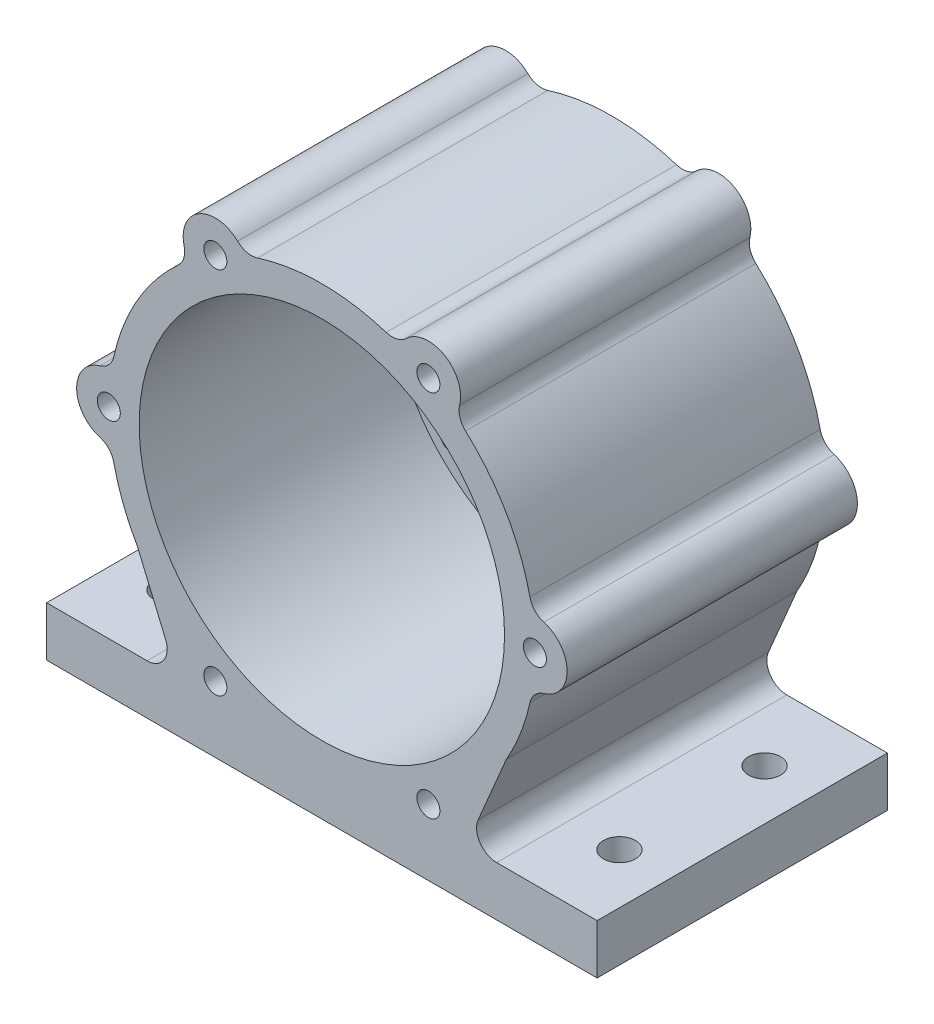
from build123d import *

# Parameters (mm, degrees)
SKETCH1_R          = 24.5
SKETCH1_R_2        = 18.25
SKETCH1_R_3        = 1.15
SHELL_DEPTH        = 25
SKETCH2_R          = 24.5
SKETCH2_R_2        = 7.25
FRONT_FACE_DEPTH   = 4
FRONT_CUTOUT_REACH = 6
SKETCH4_R          = 47.662940576
CUT_EXTRUDE2_DEPTH = 30
FOOT_DEPTH         = 29
CUT_EXTRUDE3_REACH = 6.965
SKETCH6_R          = 1.6


with BuildPart() as part:
    # Sketch1 → Shell (new body)
    with BuildSketch(Plane.XY):
        Circle(SKETCH1_R)
        Circle(SKETCH1_R_2, mode=Mode.SUBTRACT)
        with Locations((10.6425, 18.43335072)):
            Circle(SKETCH1_R_3, mode=Mode.SUBTRACT)
        with Locations((21.285, 0)):
            Circle(SKETCH1_R_3, mode=Mode.SUBTRACT)
        with Locations((10.6425, -18.43335072)):
            Circle(SKETCH1_R_3, mode=Mode.SUBTRACT)
        with Locations((-10.6425, -18.43335072)):
            Circle(SKETCH1_R_3, mode=Mode.SUBTRACT)
        with Locations((-21.285, 0)):
            Circle(SKETCH1_R_3, mode=Mode.SUBTRACT)
        with Locations((-10.6425, 18.43335072)):
            Circle(SKETCH1_R_3, mode=Mode.SUBTRACT)
    extrude(amount=SHELL_DEPTH)

    # Sketch2 → Front Face (add)
    with BuildSketch(Plane(origin=(0, 0, 0), x_dir=(-1, 0, 0), z_dir=(0, 0, -1))):
        Circle(SKETCH2_R)
        Circle(SKETCH2_R_2, mode=Mode.SUBTRACT)
    extrude(amount=FRONT_FACE_DEPTH)

    # Sketch3 → Front Cutout (cut, up to next)
    with BuildSketch(Plane.XY, mode=Mode.PRIVATE) as front_cutout_sk1:
        with BuildLine():
            Line((2.9546421, 10.808626061), (4.278048129, 15.64463523))
            ThreePointArc((4.278048129, 15.64463523), (4.166472664, 16.430562443), (3.517420663, 16.88757685))
            ThreePointArc((3.517420663, 16.88757685), (-0.005796994, 17.249999026), (-3.528770265, 16.885208924))
            ThreePointArc((-3.528770265, 16.885208924), (-4.174553562, 16.432574254), (-4.291492303, 15.652677119))
            Line((-4.291492303, 15.652677119), (-3.020759373, 10.807322517))
            ThreePointArc((-3.020759373, 10.807322517), (-2.58920538, 10.216615101), (-1.870940192, 10.077801486))
            ThreePointArc((-1.870940192, 10.077801486), (-0.029343923, 10.249957997), (1.813207862, 10.088348589))
            ThreePointArc((1.813207862, 10.088348589), (2.523766335, 10.226878689), (2.9546421, 10.808626061))
        make_face()
    front_cutout_tool1 = extrude(front_cutout_sk1.sketch, amount=-FRONT_CUTOUT_REACH, mode=Mode.PRIVATE) & part.part
    add(front_cutout_tool1.solids().sort_by_distance((-0.016979, 13.876247, 0))[0], mode=Mode.SUBTRACT)
    # Sketch3 → Front Cutout (cut, up to next)
    with BuildSketch(Plane.XY, mode=Mode.PRIVATE) as front_cutout_sk2:
        with BuildLine():
            Line((10.837865799, 2.845517913), (15.687675607, 4.117419256))
            ThreePointArc((15.687675607, 4.117419256), (16.312520806, 4.60701005), (16.383780892, 5.397612775))
            ThreePointArc((16.383780892, 5.397612775), (14.936038875, 8.630019857), (12.858634744, 11.498609156))
            ThreePointArc((12.858634744, 11.498609156), (12.143749973, 11.831556562), (11.409869871, 11.542879914))
            Line((11.409869871, 11.542879914), (7.849036161, 8.019715614))
            ThreePointArc((7.849036161, 8.019715614), (7.553245528, 7.350625185), (7.792162005, 6.659182478))
            ThreePointArc((7.792162005, 6.659182478), (8.862052051, 5.150391581), (9.643370091, 3.473890223))
            ThreePointArc((9.643370091, 3.473890223), (10.118619913, 2.927793585), (10.837865799, 2.845517913))
        make_face()
    front_cutout_tool2 = extrude(front_cutout_sk2.sketch, amount=-FRONT_CUTOUT_REACH, mode=Mode.PRIVATE) & part.part
    add(front_cutout_tool2.solids().sort_by_distance((12.008692, 6.952828, 0))[0], mode=Mode.SUBTRACT)
    # Sketch3 → Front Cutout (cut, up to next)
    with BuildSketch(Plane.XY, mode=Mode.PRIVATE) as front_cutout_sk3:
        with BuildLine():
            Line((7.883223699, -7.963108149), (11.409627477, -11.527215974))
            ThreePointArc((11.409627477, -11.527215974), (12.146048142, -11.823552392), (12.866360229, -11.489964075))
            ThreePointArc((12.866360229, -11.489964075), (14.941835869, -8.619979169), (16.387405009, -5.386599768))
            ThreePointArc((16.387405009, -5.386599768), (16.318303535, -4.601017693), (15.701362174, -4.109797205))
            Line((15.701362174, -4.109797205), (10.869795533, -2.787606903))
            ThreePointArc((10.869795533, -2.787606903), (10.142450908, -2.865989916), (9.663102197, -3.418619008))
            ThreePointArc((9.663102197, -3.418619008), (8.891395974, -5.099566416), (7.830162229, -6.614458365))
            ThreePointArc((7.830162229, -6.614458365), (7.594853579, -7.299085103), (7.883223699, -7.963108149))
        make_face()
    front_cutout_tool3 = extrude(front_cutout_sk3.sketch, amount=-FRONT_CUTOUT_REACH, mode=Mode.PRIVATE) & part.part
    add(front_cutout_tool3.solids().sort_by_distance((12.025672, -6.923419, 0))[0], mode=Mode.SUBTRACT)
    # Sketch3 → Front Cutout (cut, up to next)
    with BuildSketch(Plane.XY, mode=Mode.PRIVATE) as front_cutout_sk4:
        with BuildLine():
            Line((-2.9546421, -10.808626061), (-4.278048129, -15.64463523))
            ThreePointArc((-4.278048129, -15.64463523), (-4.166472664, -16.430562443), (-3.517420663, -16.88757685))
            ThreePointArc((-3.517420663, -16.88757685), (0.005796994, -17.249999026), (3.528770265, -16.885208924))
            ThreePointArc((3.528770265, -16.885208924), (4.174553562, -16.432574254), (4.291492303, -15.652677119))
            Line((4.291492303, -15.652677119), (3.020759373, -10.807322517))
            ThreePointArc((3.020759373, -10.807322517), (2.58920538, -10.216615101), (1.870940192, -10.077801486))
            ThreePointArc((1.870940192, -10.077801486), (0.029343923, -10.249957997), (-1.813207862, -10.088348589))
            ThreePointArc((-1.813207862, -10.088348589), (-2.523766335, -10.226878689), (-2.9546421, -10.808626061))
        make_face()
    front_cutout_tool4 = extrude(front_cutout_sk4.sketch, amount=-FRONT_CUTOUT_REACH, mode=Mode.PRIVATE) & part.part
    add(front_cutout_tool4.solids().sort_by_distance((0.016979, -13.876247, 0))[0], mode=Mode.SUBTRACT)
    # Sketch3 → Front Cutout (cut, up to next)
    with BuildSketch(Plane.XY, mode=Mode.PRIVATE) as front_cutout_sk5:
        with BuildLine():
            Line((-10.837865799, -2.845517913), (-15.687675607, -4.117419256))
            ThreePointArc((-15.687675607, -4.117419256), (-16.312520806, -4.60701005), (-16.383780892, -5.397612775))
            ThreePointArc((-16.383780892, -5.397612775), (-14.936038875, -8.630019857), (-12.858634744, -11.498609156))
            ThreePointArc((-12.858634744, -11.498609156), (-12.143749973, -11.831556562), (-11.409869871, -11.542879914))
            Line((-11.409869871, -11.542879914), (-7.849036161, -8.019715614))
            ThreePointArc((-7.849036161, -8.019715614), (-7.553245528, -7.350625185), (-7.792162005, -6.659182478))
            ThreePointArc((-7.792162005, -6.659182478), (-8.862052051, -5.150391581), (-9.643370091, -3.473890223))
            ThreePointArc((-9.643370091, -3.473890223), (-10.118619913, -2.927793585), (-10.837865799, -2.845517913))
        make_face()
    front_cutout_tool5 = extrude(front_cutout_sk5.sketch, amount=-FRONT_CUTOUT_REACH, mode=Mode.PRIVATE) & part.part
    add(front_cutout_tool5.solids().sort_by_distance((-12.008692, -6.952828, 0))[0], mode=Mode.SUBTRACT)
    # Sketch3 → Front Cutout (cut, up to next)
    with BuildSketch(Plane.XY, mode=Mode.PRIVATE) as front_cutout_sk6:
        with BuildLine():
            Line((-7.883223699, 7.963108149), (-11.409627477, 11.527215974))
            ThreePointArc((-11.409627477, 11.527215974), (-12.146048142, 11.823552392), (-12.866360229, 11.489964075))
            ThreePointArc((-12.866360229, 11.489964075), (-14.941835869, 8.619979169), (-16.387405009, 5.386599768))
            ThreePointArc((-16.387405009, 5.386599768), (-16.318303535, 4.601017693), (-15.701362174, 4.109797205))
            Line((-15.701362174, 4.109797205), (-10.869795533, 2.787606903))
            ThreePointArc((-10.869795533, 2.787606903), (-10.142450908, 2.865989916), (-9.663102197, 3.418619008))
            ThreePointArc((-9.663102197, 3.418619008), (-8.891395974, 5.099566416), (-7.830162229, 6.614458365))
            ThreePointArc((-7.830162229, 6.614458365), (-7.594853579, 7.299085103), (-7.883223699, 7.963108149))
        make_face()
    front_cutout_tool6 = extrude(front_cutout_sk6.sketch, amount=-FRONT_CUTOUT_REACH, mode=Mode.PRIVATE) & part.part
    add(front_cutout_tool6.solids().sort_by_distance((-12.025672, 6.923419, 0))[0], mode=Mode.SUBTRACT)

    # Sketch4 → Cut-Extrude2 (cut, through all)
    with BuildSketch(Plane.XY.offset(25)):
        Circle(SKETCH4_R)
        with BuildLine():
            ThreePointArc((-14.357896922, 15.713116209), (-18.43335072, 10.6425), (-20.78690627, 4.577745375))
            ThreePointArc((-20.78690627, 4.577745375), (-21.279990354, 3.641110586), (-22.182058329, 3.087314586))
            ThreePointArc((-22.182058329, 3.087314586), (-24.5, 0), (-22.182058329, -3.087314586))
            ThreePointArc((-22.182058329, -3.087314586), (-21.279990354, -3.641110586), (-20.78690627, -4.577745375))
            ThreePointArc((-20.78690627, -4.577745375), (-18.43335072, -10.6425), (-14.357896922, -15.713116209))
            ThreePointArc((-14.357896922, -15.713116209), (-13.793289442, -16.608456946), (-13.764722026, -17.666568728))
            ThreePointArc((-13.764722026, -17.666568728), (-12.25, -21.217622393), (-8.417336304, -20.753883315))
            ThreePointArc((-8.417336304, -20.753883315), (-7.486700912, -20.249567531), (-6.429009348, -20.290861583))
            ThreePointArc((-6.429009348, -20.290861583), (0, -21.285), (6.429009348, -20.290861583))
            ThreePointArc((6.429009348, -20.290861583), (7.486700912, -20.249567531), (8.417336304, -20.753883315))
            ThreePointArc((8.417336304, -20.753883315), (12.25, -21.217622393), (13.764722026, -17.666568728))
            ThreePointArc((13.764722026, -17.666568728), (13.793289442, -16.608456946), (14.357896922, -15.713116209))
            ThreePointArc((14.357896922, -15.713116209), (18.43335072, -10.6425), (20.78690627, -4.577745375))
            ThreePointArc((20.78690627, -4.577745375), (21.279990354, -3.641110586), (22.182058329, -3.087314586))
            ThreePointArc((22.182058329, -3.087314586), (24.5, 0), (22.182058329, 3.087314586))
            ThreePointArc((22.182058329, 3.087314586), (21.279990354, 3.641110586), (20.78690627, 4.577745375))
            ThreePointArc((20.78690627, 4.577745375), (18.43335072, 10.6425), (14.357896922, 15.713116209))
            ThreePointArc((14.357896922, 15.713116209), (13.793289442, 16.608456946), (13.764722026, 17.666568728))
            ThreePointArc((13.764722026, 17.666568728), (12.25, 21.217622393), (8.417336304, 20.753883315))
            ThreePointArc((8.417336304, 20.753883315), (7.486700912, 20.249567531), (6.429009348, 20.290861583))
            ThreePointArc((6.429009348, 20.290861583), (0, 21.285), (-6.429009348, 20.290861583))
            ThreePointArc((-6.429009348, 20.290861583), (-7.486700912, 20.249567531), (-8.417336304, 20.753883315))
            ThreePointArc((-8.417336304, 20.753883315), (-12.25, 21.217622393), (-13.764722026, 17.666568728))
            ThreePointArc((-13.764722026, 17.666568728), (-13.793289442, 16.608456946), (-14.357896922, 15.713116209))
        make_face(mode=Mode.SUBTRACT)
    extrude(amount=-CUT_EXTRUDE2_DEPTH, mode=Mode.SUBTRACT)

    # Sketch5 → Foot (add)
    with BuildSketch(Plane.XY.offset(25)):
        with BuildLine():
            Line((-27.5, -25.036296311), (27.5, -25.036296311))
            Line((27.5, -25.036296311), (27.5, -20.070839215))
            Line((27.5, -20.070839215), (17.456181219, -20.070839215))
            ThreePointArc((17.456181219, -20.070839215), (15.788638495, -19.175058967), (15.614847604, -17.290140477))
            Line((15.614847604, -17.290140477), (18.43335072, -10.6425))
            ThreePointArc((18.43335072, -10.6425), (16.590487264, -13.334427522), (14.357896922, -15.713116209))
            ThreePointArc((14.357896922, -15.713116209), (13.793289442, -16.608456946), (13.764722026, -17.666568728))
            ThreePointArc((13.764722026, -17.666568728), (12.25, -21.217622393), (8.417336304, -20.753883315))
            ThreePointArc((8.417336304, -20.753883315), (7.486700912, -20.249567531), (6.429009348, -20.290861583))
            ThreePointArc((6.429009348, -20.290861583), (0, -21.285), (-6.429009348, -20.290861583))
            ThreePointArc((-6.429009348, -20.290861583), (-7.486700912, -20.249567531), (-8.417336304, -20.753883315))
            ThreePointArc((-8.417336304, -20.753883315), (-12.25, -21.217622393), (-13.764722026, -17.666568728))
            ThreePointArc((-13.764722026, -17.666568728), (-13.793289442, -16.608456946), (-14.357896922, -15.713116209))
            ThreePointArc((-14.357896922, -15.713116209), (-16.590487264, -13.334427522), (-18.43335072, -10.6425))
            Line((-18.43335072, -10.6425), (-15.614847604, -17.290140477))
            ThreePointArc((-15.614847604, -17.290140477), (-15.788638495, -19.175058967), (-17.456181219, -20.070839215))
            Line((-17.456181219, -20.070839215), (-27.5, -20.070839215))
            Line((-27.5, -20.070839215), (-27.5, -25.036296311))
        make_face()
    extrude(amount=-FOOT_DEPTH)

    # Sketch6 → Cut-Extrude3 (cut, up to next)
    with BuildSketch(Plane(origin=(0, -20.070839215, 0), x_dir=(1, 0, 0), z_dir=(0, 1, 0)), mode=Mode.PRIVATE) as cut_extrude3_sk1:
        with Locations((22.47809061, -17.75)):
            Circle(SKETCH6_R)
    cut_extrude3_tool1 = extrude(cut_extrude3_sk1.sketch, amount=-CUT_EXTRUDE3_REACH, mode=Mode.PRIVATE) & part.part
    add(cut_extrude3_tool1.solids().sort_by_distance((22.478091, -20.070839, 17.75))[0], mode=Mode.SUBTRACT)
    # Sketch6 → Cut-Extrude3 (cut, up to next)
    with BuildSketch(Plane(origin=(0, -20.070839215, 0), x_dir=(1, 0, 0), z_dir=(0, 1, 0)), mode=Mode.PRIVATE) as cut_extrude3_sk2:
        with Locations((22.47809061, -3.25)):
            Circle(SKETCH6_R)
    cut_extrude3_tool2 = extrude(cut_extrude3_sk2.sketch, amount=-CUT_EXTRUDE3_REACH, mode=Mode.PRIVATE) & part.part
    add(cut_extrude3_tool2.solids().sort_by_distance((22.478091, -20.070839, 3.25))[0], mode=Mode.SUBTRACT)
    # Sketch6 → Cut-Extrude3 (cut, up to next)
    with BuildSketch(Plane(origin=(0, -20.070839215, 0), x_dir=(1, 0, 0), z_dir=(0, 1, 0)), mode=Mode.PRIVATE) as cut_extrude3_sk3:
        with Locations((-22.47809061, -17.75)):
            Circle(SKETCH6_R)
    cut_extrude3_tool3 = extrude(cut_extrude3_sk3.sketch, amount=-CUT_EXTRUDE3_REACH, mode=Mode.PRIVATE) & part.part
    add(cut_extrude3_tool3.solids().sort_by_distance((-22.478091, -20.070839, 17.75))[0], mode=Mode.SUBTRACT)
    # Sketch6 → Cut-Extrude3 (cut, up to next)
    with BuildSketch(Plane(origin=(0, -20.070839215, 0), x_dir=(1, 0, 0), z_dir=(0, 1, 0)), mode=Mode.PRIVATE) as cut_extrude3_sk4:
        with Locations((-22.47809061, -3.25)):
            Circle(SKETCH6_R)
    cut_extrude3_tool4 = extrude(cut_extrude3_sk4.sketch, amount=-CUT_EXTRUDE3_REACH, mode=Mode.PRIVATE) & part.part
    add(cut_extrude3_tool4.solids().sort_by_distance((-22.478091, -20.070839, 3.25))[0], mode=Mode.SUBTRACT)


solid = part.part
